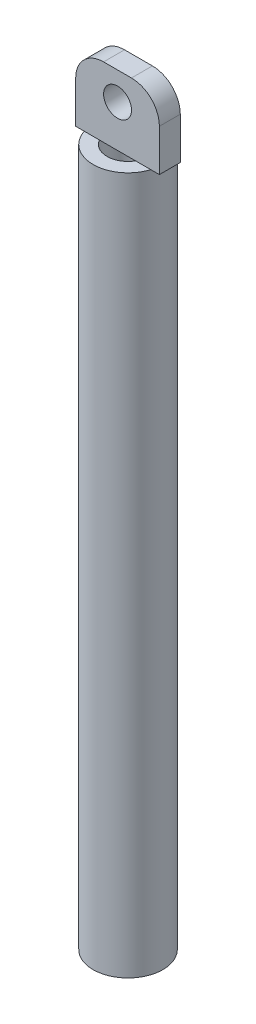
from build123d import *

# Parameters (mm, degrees)
SKETCH1_R           = 2.5
SKETCH1_R_2         = 1.5
BOSS_EXTRUDE1_DEPTH = 50
SKETCH2_W           = 6
SKETCH2_H           = 1.5
BOSS_EXTRUDE2_DEPTH = 5
SKETCH3_R           = 1
CUT_EXTRUDE1_DEPTH  = 4.25
FILLET1_R           = 2


with BuildPart() as part:
    # Sketch1 → Boss-Extrude1 (new body)
    with BuildSketch(Plane(origin=(0, 0, 0), x_dir=(1, 0, 0), z_dir=(0, 1, 0))):
        Circle(SKETCH1_R)
        Circle(SKETCH1_R_2, mode=Mode.SUBTRACT)
    extrude(amount=BOSS_EXTRUDE1_DEPTH)

    # Sketch2 → Boss-Extrude2 (add)
    with BuildSketch(Plane(origin=(0, 50, 0), x_dir=(1, 0, 0), z_dir=(0, 1, 0))):
        Rectangle(SKETCH2_W, SKETCH2_H)
    extrude(amount=BOSS_EXTRUDE2_DEPTH)

    # Sketch3 → Cut-Extrude1 (cut, through all)
    with BuildSketch(Plane(origin=(0, 0, -0.75), x_dir=(-1, 0, 0), z_dir=(0, 0, -1))):
        with Locations((0, 53)):
            Circle(SKETCH3_R)
    extrude(amount=-CUT_EXTRUDE1_DEPTH, mode=Mode.SUBTRACT)

    # Fillet1
    fillet1_edges = [part.edges().sort_by_distance(p)[0] for p in [
        (3, 55, 0),
        (-3, 55, 0),
    ]]
    fillet(fillet1_edges, radius=FILLET1_R)


solid = part.part
